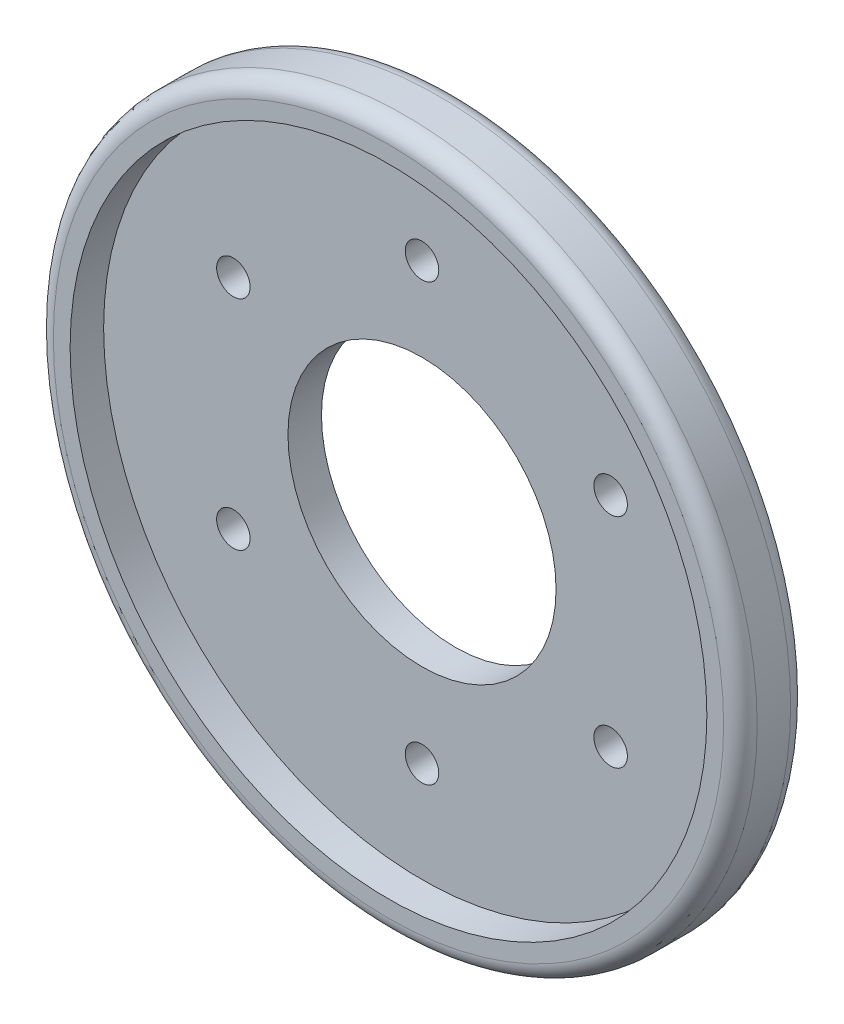
from build123d import *

# Parameters (mm, degrees)
SKETCH_1_R          = 21
SKETCH_1_R_2        = 8
EXTRUDE_1_DEPTH     = 2
EXTRUDE_3_DEPTH     = 4
FILLET_1_R          = 1
SKETCH_3_R          = 1
CUT_EXTRUDE_2_DEPTH = 3


with BuildPart() as part:
    # Эскиз1 → Бобышка-Вытянуть1 (new body)
    with BuildSketch(Plane.XY):
        Circle(SKETCH_1_R)
        Circle(SKETCH_1_R_2, mode=Mode.SUBTRACT)
    extrude(amount=EXTRUDE_1_DEPTH)

    # Эскиз1<5> → Бобышка-Вытянуть3 (add)
    with BuildSketch(Plane.XY):
        with BuildLine():
            ThreePointArc((0, -19), (-19, 0), (0, 19))
            Line((0, 19), (0, 21))
            ThreePointArc((0, 21), (-21, 0), (0, -21))
            Line((0, -21), (0, -19))
        make_face()
        with BuildLine():
            Line((0, 21), (0, 19))
            ThreePointArc((0, 19), (13.435028843, 13.435028843), (19, 0))
            ThreePointArc((19, 0), (13.435028843, -13.435028843), (0, -19))
            Line((0, -19), (0, -21))
            ThreePointArc((0, -21), (14.849242405, -14.849242405), (21, 0))
            ThreePointArc((21, 0), (14.849242405, 14.849242405), (0, 21))
        make_face()
    extrude(amount=EXTRUDE_3_DEPTH)

    # Скругление1
    fillet_1_edges = [part.edges().sort_by_distance(p)[0] for p in [
        (0, 21, 4),
        (-21, 0, 0),
    ]]
    fillet(fillet_1_edges, radius=FILLET_1_R)

    # Эскиз3 → Вырез-Вытянуть2 (cut, through all)
    with BuildSketch(Plane.XY.offset(2)):
        with Locations((11.257055761, 6.499264174)):
            Circle(SKETCH_3_R)
        with Locations((11.257055761, -6.499264174)):
            Circle(SKETCH_3_R)
        with Locations((0, -12.998528347)):
            Circle(SKETCH_3_R)
        with Locations((-11.257055761, -6.499264174)):
            Circle(SKETCH_3_R)
        with Locations((0, 12.998528347)):
            Circle(SKETCH_3_R)
        with Locations((-11.257055761, 6.499264174)):
            Circle(SKETCH_3_R)
    extrude(amount=-CUT_EXTRUDE_2_DEPTH, mode=Mode.SUBTRACT)


solid = part.part
